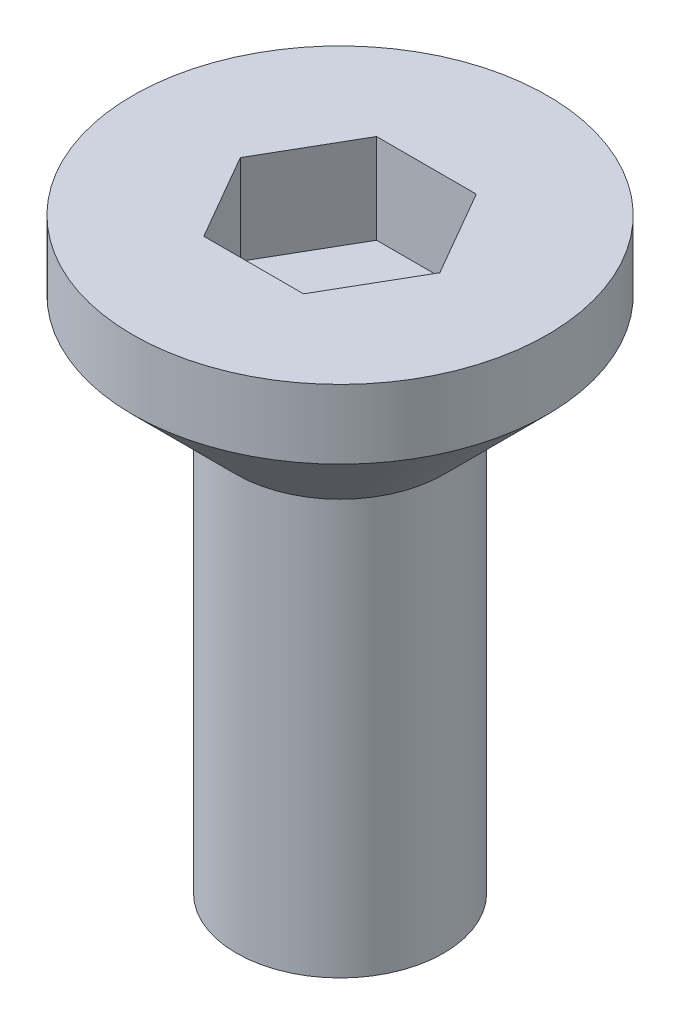
from build123d import *

# Parameters (mm, degrees)
SKETCH_1_R            = 3
EXTRUDE_251_DEPTH     = 2.5
CHAMFER_1_SIZE        = 1.5
CUT_EXTRUDE_459_DEPTH = 1.3
SKETCH_3_R            = 1.5
EXTRUDE_571_DEPTH     = 6


with BuildPart() as part:
    # 草图1 → Extrude 251 (new body)
    with BuildSketch(Plane(origin=(0, 0, 0), x_dir=(1, 0, 0), z_dir=(0, 1, 0))):
        Circle(SKETCH_1_R)
    extrude(amount=EXTRUDE_251_DEPTH)

    # 倒角1
    chamfer_1_edges = [part.edges().sort_by_distance(p)[0] for p in [
        (-3, 0, 0),
    ]]
    chamfer(chamfer_1_edges, length=CHAMFER_1_SIZE)

    # 草图2 → Cut-Extrude 459 (cut)
    with BuildSketch(Plane(origin=(0, 2.5, 0), x_dir=(1, 0, 0), z_dir=(0, 1, 0))):
        Polygon((1.443375673, 0), (0.721687836, 1.25), (-0.721687836, 1.25), (-1.443375673, 0), (-0.721687836, -1.25), (0.721687836, -1.25), align=None)
    extrude(amount=-CUT_EXTRUDE_459_DEPTH, mode=Mode.SUBTRACT)

    # 草图3 → Extrude 571 (add)
    with BuildSketch(Plane.XZ):
        Circle(SKETCH_3_R)
    extrude(amount=EXTRUDE_571_DEPTH)


solid = part.part
